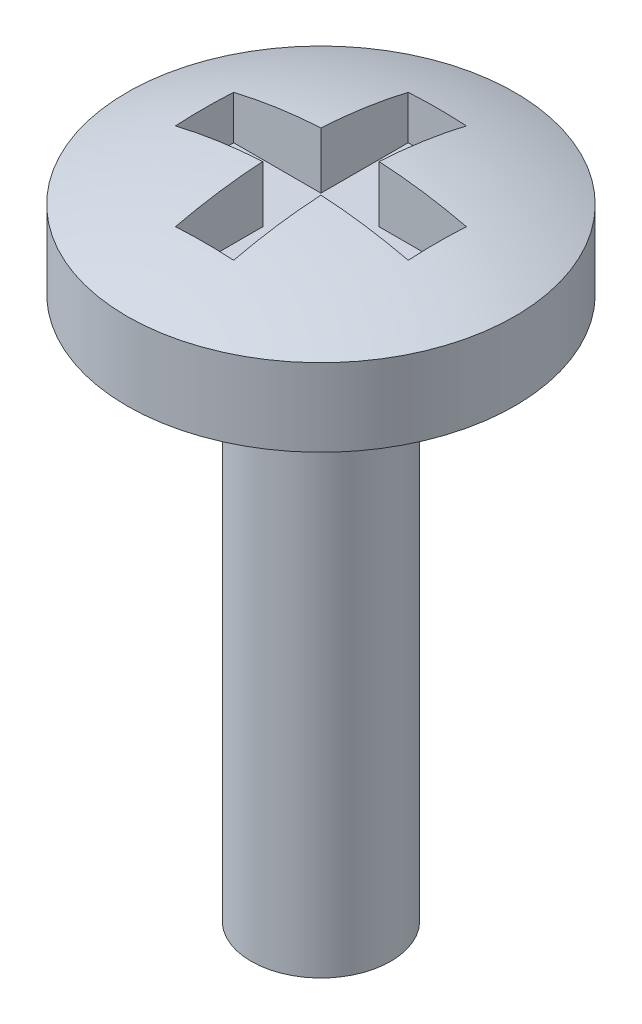
from build123d import *

# Parameters (mm, degrees)
SKETCH1_R           = 0.9
BOSS_EXTRUDE1_DEPTH = 7
SKETCH2_R           = 2.5
BOSS_EXTRUDE2_DEPTH = 1
DOME1_FACE_RADIUS   = 2.5
DOME1_HEIGHT        = 0.5
SKETCH3_W           = 1.125
SKETCH3_H           = 0.75
SKETCH3_W_2         = 0.75
SKETCH3_H_2         = 1.125
CUT_EXTRUDE1_DEPTH  = 0.75


with BuildPart() as part:
    # Sketch1 → Boss-Extrude1 (new body)
    with BuildSketch(Plane(origin=(0, 0, 0), x_dir=(1, 0, 0), z_dir=(0, 1, 0))):
        Circle(SKETCH1_R)
    extrude(amount=BOSS_EXTRUDE1_DEPTH)

    # Sketch2 → Boss-Extrude2 (add)
    with BuildSketch(Plane(origin=(0, 7, 0), x_dir=(1, 0, 0), z_dir=(0, 1, 0))):
        Circle(SKETCH2_R)
    extrude(amount=BOSS_EXTRUDE2_DEPTH)

    # Dome1: a dome of height H over a round flat face of radius A is a cap of a sphere of radius (A * A + H * H) / (2 * H)
    dome1_r = (DOME1_FACE_RADIUS * DOME1_FACE_RADIUS + DOME1_HEIGHT * DOME1_HEIGHT) / (2 * DOME1_HEIGHT)
    dome1_base = Plane((0, 8, 0), z_dir=(0, 1, 0))
    with Locations(dome1_base.offset(DOME1_HEIGHT - dome1_r)):
        dome1_ball = Sphere(dome1_r, mode=Mode.PRIVATE)
    add(split(dome1_ball, bisect_by=dome1_base, keep=Keep.TOP, mode=Mode.PRIVATE))

    # Sketch3 → Cut-Extrude1 (cut)
    with BuildSketch(Plane(origin=(0, 8.5, 0), x_dir=(1, 0, 0), z_dir=(0, 1, 0))):
        with Locations((-0.9375, 0)):
            Rectangle(SKETCH3_W, SKETCH3_H)
        Rectangle(SKETCH3_W_2, SKETCH3_H)
        with Locations((0, 0.9375)):
            Rectangle(SKETCH3_W_2, SKETCH3_H_2)
        with Locations((0.9375, 0)):
            Rectangle(SKETCH3_W, SKETCH3_H)
        with Locations((0, -0.9375)):
            Rectangle(SKETCH3_W_2, SKETCH3_H_2)
    extrude(amount=-CUT_EXTRUDE1_DEPTH, mode=Mode.SUBTRACT)


solid = part.part
